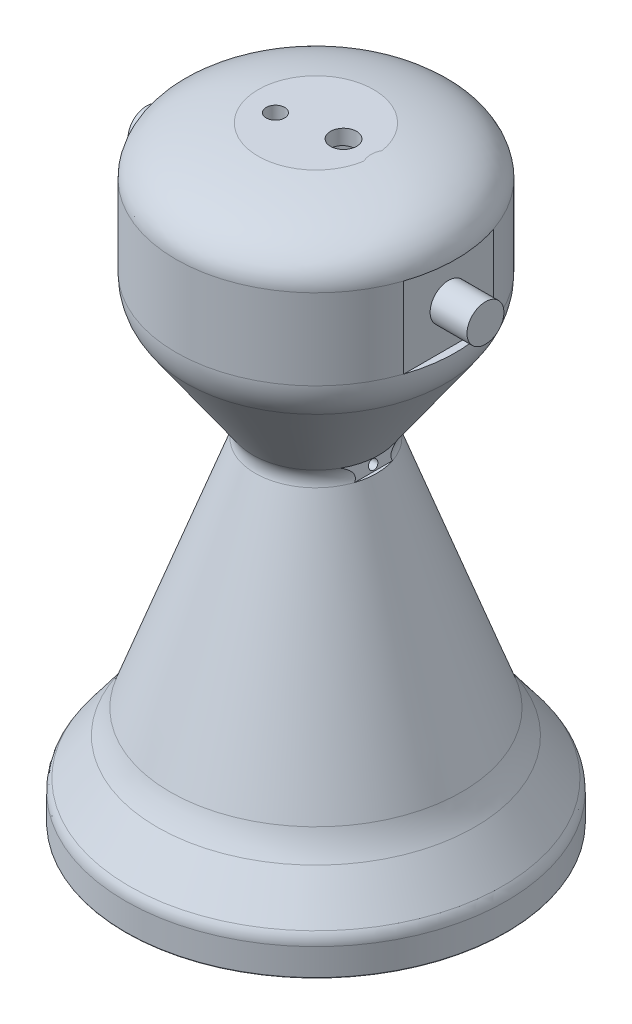
from build123d import *

# Parameters (mm, degrees)
CUT_EXTRUDE1_DEPTH      = 104.255693004
CUT_EXTRUDE1_DEPTH_BACK = 104.255693004
CUT_EXTRUDE2_REACH      = 330.714
SKETCH3_R               = 7.071067812
SKETCH3_R_2             = 5
CUT_EXTRUDE4_DEPTH      = 104.255693004
CUT_EXTRUDE4_DEPTH_BACK = 104.255693004
CUT_EXTRUDE5_REACH      = 162.61
SKETCH5_R               = 2.5
CUT_EXTRUDE6_DEPTH      = 104.255693004
CUT_EXTRUDE6_DEPTH_BACK = 104.255693004
CUT_EXTRUDE8_DEPTH      = 104.255693004
CUT_EXTRUDE8_DEPTH_BACK = 104.255693004
SKETCH9_R               = 10
BOSS_EXTRUDE1_DEPTH     = 20
SKETCH10_R              = 10
BOSS_EXTRUDE2_DEPTH     = 20


with BuildPart() as part:
    # Sketch1 → Revolve1 (revolve)
    with BuildSketch(Plane.XY):
        with BuildLine():
            Line((23.560888345, -9.783460321), (55.982458505, -98.860992239))
            Line((55.982458505, -98.860992239), (95.300521444, -186.755203806))
            ThreePointArc((95.300521444, -186.755203806), (95.484985115, -186.970608057), (95.756936438, -187.051033894))
            Line((95.756936438, -187.051033894), (102.755692904, -187.051033894))
            ThreePointArc((102.755692904, -187.051033894), (103.109246295, -186.904587285), (103.255692904, -186.551033894))
            Line((103.255692904, -186.551033894), (103.255692904, -172.072092881))
            ThreePointArc((103.255692904, -172.072092881), (102.738929456, -168.899046317), (101.242048004, -166.053942649))
            Line((101.242048004, -166.053942649), (86.084068354, -145.938624248))
            ThreePointArc((86.084068354, -145.938624248), (82.074988223, -139.705811103), (79.031212817, -132.948880257))
            Line((79.031212817, -132.948880257), (32.957814553, -6.363258887))
            ThreePointArc((32.957814553, -6.363258887), (32.440292147, -1.637795532), (34.163220318, 2.792706909))
            Line((34.163220318, 2.792706909), (70.460676237, 54.63084623))
            ThreePointArc((70.460676237, 54.63084623), (74.497623431, 62.816965336), (75.886114908, 71.838139321))
            Line((75.886114908, 71.838139321), (75.886114908, 115.532163543))
            add(Edge.make_bspline(
                [(0, 143.746721451), (2.243591022, 143.746721451), (6.741094716, 143.685705734), (15.648562627, 143.320496354), (26.499723252, 142.411729196), (38.630004208, 140.62259877), (49.505345526, 138.161778685), (57.307005523, 135.553502748), (62.762629698, 133.047210246), (66.480873303, 130.888623038), (69.846974194, 128.319352515), (72.840918039, 125.097883065), (74.818077713, 121.554294304), (75.72594574, 118.203296667), (75.886114908, 116.416718913), (75.886114908, 115.532163543)],
                knots=[0, 0, 0, 0, 0.09817477, 0.196349541, 0.392699082, 0.589048623, 0.785398163, 0.981747704, 1.079922475, 1.178097245, 1.276272016, 1.374446786, 1.472621556, 1.521708942, 1.570796327, 1.570796327, 1.570796327, 1.570796327], degree=3))
            Line((0, 143.746721451), (0, 133.746721451))
            add(Edge.make_bspline(
                [(65.886114908, 115.532163543), (65.886114908, 133.746721451), (0, 133.746721451)],
                knots=[0, 0, 0, 1.570796327, 1.570796327, 1.570796327], degree=2, weights=[1, 0.707106781, 1]))
            Line((65.886114908, 115.532163543), (65.886114908, 71.838139321))
            ThreePointArc((65.886114908, 71.838139321), (64.960453923, 65.824023331), (62.269155794, 60.366610594))
            Line((62.269155794, 60.366610594), (25.971699875, 8.528471273))
            ThreePointArc((25.971699875, 8.528471273), (22.525843533, -0.33253361), (23.560888345, -9.783460321))
        make_face()
    revolve(axis=Axis((0, 149.929333896, 0), (0, -1, 0)))

    # Sketch2 → Cut-Extrude1 (cut, two sides)
    with BuildSketch(Plane.XY) as cut_extrude1_sk:
        Polygon((-31.314100391, 141.662673258), (30.934664561, 141.662673258), (-13.694810222, 150.033108077), align=None)
    extrude(amount=CUT_EXTRUDE1_DEPTH, mode=Mode.SUBTRACT)
    extrude(cut_extrude1_sk.sketch, amount=-CUT_EXTRUDE1_DEPTH_BACK, mode=Mode.SUBTRACT)

    # Sketch3 → Cut-Extrude2 (cut, up to next)
    with BuildSketch(Plane(origin=(0, 141.662673258, 0), x_dir=(1, 0, 0), z_dir=(0, 1, 0)), mode=Mode.PRIVATE) as cut_extrude2_sk1:
        with Locations((14.953270005, 0)):
            Circle(SKETCH3_R)
    cut_extrude2_tool1 = extrude(cut_extrude2_sk1.sketch, amount=-CUT_EXTRUDE2_REACH, mode=Mode.PRIVATE) & part.part
    add(cut_extrude2_tool1.solids().sort_by_distance((14.95327, 141.662673, 0))[0], mode=Mode.SUBTRACT)
    # Sketch3 → Cut-Extrude2 (cut, up to next)
    with BuildSketch(Plane(origin=(0, 141.662673258, 0), x_dir=(1, 0, 0), z_dir=(0, 1, 0)), mode=Mode.PRIVATE) as cut_extrude2_sk2:
        with Locations((-15.781127398, -6.168986165)):
            Circle(SKETCH3_R_2)
    cut_extrude2_tool2 = extrude(cut_extrude2_sk2.sketch, amount=-CUT_EXTRUDE2_REACH, mode=Mode.PRIVATE) & part.part
    add(cut_extrude2_tool2.solids().sort_by_distance((-15.781127, 141.662673, 6.168986))[0], mode=Mode.SUBTRACT)

    # Sketch4 → Cut-Extrude4 (cut, two sides)
    with BuildSketch(Plane.XY) as cut_extrude4_sk:
        Polygon((34.163220318, 2.792706909), (29.881963174, 2.792706909), (31.299148565, -6.363258887), (32.957814553, -6.363258887), align=None)
    extrude(amount=CUT_EXTRUDE4_DEPTH, mode=Mode.SUBTRACT)
    extrude(cut_extrude4_sk.sketch, amount=-CUT_EXTRUDE4_DEPTH_BACK, mode=Mode.SUBTRACT)

    # Sketch5 → Cut-Extrude5 (cut, up to next)
    with BuildSketch(Plane(origin=(29.604959423, 4.582336471, 0), x_dir=(0, 0, -1), z_dir=(0.988232183, 0.152961276, 0)), mode=Mode.PRIVATE) as cut_extrude5_sk1:
        with Locations((0.184233006, -8.050933026)):
            Circle(SKETCH5_R)
    cut_extrude5_tool1 = extrude(cut_extrude5_sk1.sketch, amount=-CUT_EXTRUDE5_REACH, mode=Mode.PRIVATE) & part.part
    add(cut_extrude5_tool1.solids().sort_by_distance((30.83644, -3.373855, -0.184233))[0], mode=Mode.SUBTRACT)

    # Sketch7 → Cut-Extrude6 (cut, two sides)
    with BuildSketch(Plane.XY) as cut_extrude6_sk:
        Polygon((789.159543208, 115.532163543), (75.886114908, 115.532163543), (71.886114908, 115.532163543), (71.886114908, 71.838139321), (75.886114908, 71.838139321), (789.159543208, 71.838139321), (2215.706399806, 71.838139321), (2215.706399806, 115.532163543), align=None)
    extrude(amount=CUT_EXTRUDE6_DEPTH, mode=Mode.SUBTRACT)
    extrude(cut_extrude6_sk.sketch, amount=-CUT_EXTRUDE6_DEPTH_BACK, mode=Mode.SUBTRACT)

    # Sketch8 → Cut-Extrude8 (cut, two sides)
    with BuildSketch(Plane.XY) as cut_extrude8_sk:
        Polygon((-789.159543309, 115.532163543), (-75.886114908, 115.532163543), (-71.886114908, 115.532163543), (-71.886114908, 71.838139321), (-75.886114908, 71.838139321), (-789.159543309, 71.838139321), (-2215.706400112, 71.838139321), (-2215.706400112, 115.532163543), align=None)
    extrude(amount=CUT_EXTRUDE8_DEPTH, mode=Mode.SUBTRACT)
    extrude(cut_extrude8_sk.sketch, amount=-CUT_EXTRUDE8_DEPTH_BACK, mode=Mode.SUBTRACT)

    # Sketch9 → Boss-Extrude1 (add)
    with BuildSketch(Plane(origin=(71.886114908, 0, 0), x_dir=(0, 0, -1), z_dir=(1, 0, 0))):
        with Locations((0, 93.685151432)):
            Circle(SKETCH9_R)
    extrude(amount=BOSS_EXTRUDE1_DEPTH)

    # Sketch10 → Boss-Extrude2 (add)
    with BuildSketch(Plane.ZY.offset(71.886114908)):
        with Locations((0, 93.685151432)):
            Circle(SKETCH10_R)
    extrude(amount=BOSS_EXTRUDE2_DEPTH)


solid = part.part
